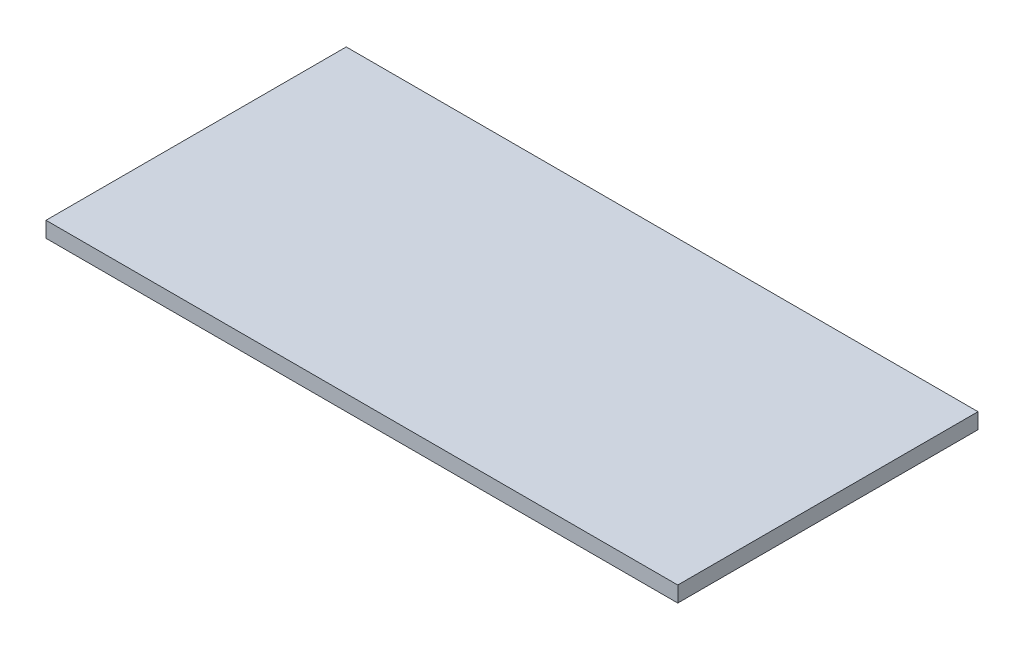
from build123d import *

# Parameters (mm, degrees)
SKETCH1_W           = 121.0056
SKETCH1_H           = 57.5056
BOSS_EXTRUDE1_DEPTH = 2.9972


with BuildPart() as part:
    # Sketch1 → Boss-Extrude1 (new body)
    with BuildSketch(Plane(origin=(0, 0, 0), x_dir=(1, 0, 0), z_dir=(0, 1, 0))):
        with Locations((60.5028, -28.7528)):
            Rectangle(SKETCH1_W, SKETCH1_H)
    extrude(amount=BOSS_EXTRUDE1_DEPTH)


solid = part.part
